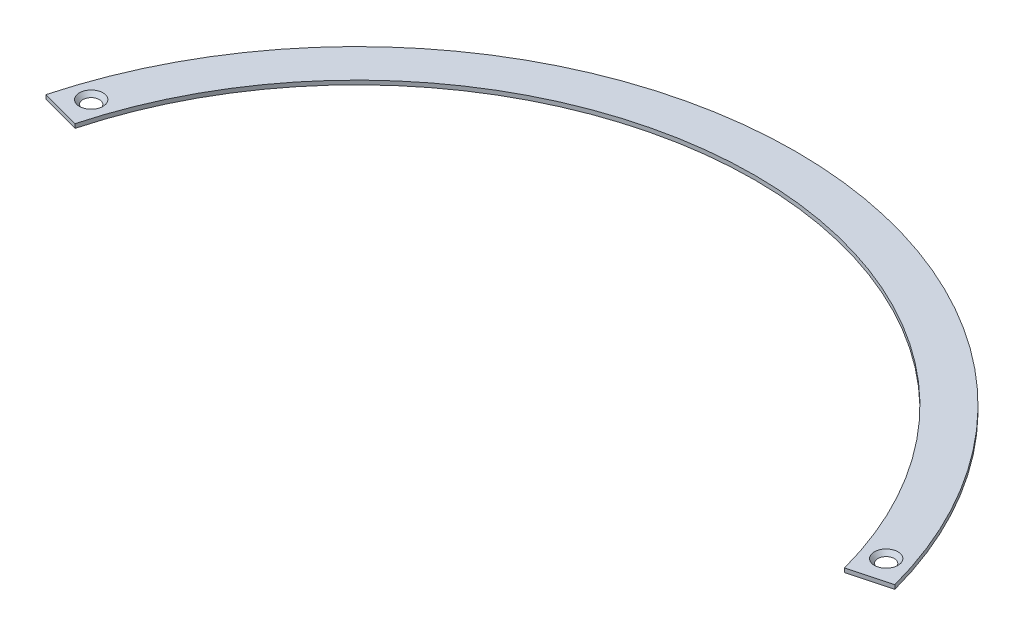
from build123d import *

# Parameters (mm, degrees)
BOSS_EXTRUDE1_DEPTH                           = 1.5875
CSK_FOR_8_FLAT_HEAD_SOCKET_CAP_SCREW1_A_COUNT = 2
CSK_FOR_8_FLAT_HEAD_SOCKET_CAP_SCREW1_A_PITCH = 307.345506508


with BuildPart() as part:
    # Sketch2 → Boss-Extrude1 (new body)
    with BuildSketch(Plane(origin=(0, 0, 0), x_dir=(1, 0, 0), z_dir=(0, 1, 0))):
        with BuildLine():
            Line((-148.740503176, 39.854897708), (-164.074575668, 43.963650049))
            ThreePointArc((-164.074575668, 43.963650049), (0, 169.8625), (164.074575668, 43.963650049))
            Line((164.074575668, 43.963650049), (148.740503176, 39.854897708))
            ThreePointArc((148.740503176, 39.854897708), (0, 153.9875), (-148.740503176, 39.854897708))
        make_face()
    extrude(amount=BOSS_EXTRUDE1_DEPTH)

    # Sketch4 → CSK for #8 Flat Head Socket Cap Screw1 (revolve, cut)
    with BuildSketch(Plane(origin=(-153.672753254, 1.5875, -51.033229688), x_dir=(0, 0, 1), z_dir=(1, 0, 0))):
        Polygon((0, 0), (0, 1.5875), (2.2479, 1.5875), (2.2479, 2.658961536), (4.5593, 0), align=None)
    csk_for_8_flat_head_socket_cap_screw1 = revolve(axis=Axis((-153.672753254, 7.9375, -51.033229688), (0, -1, 0)), mode=Mode.SUBTRACT)

    # CSK for #8 Flat Head Socket Cap Screw1 a: CSK for #8 Flat Head Socket Cap Screw1 ×2
    with Locations(*[(i * CSK_FOR_8_FLAT_HEAD_SOCKET_CAP_SCREW1_A_PITCH, 0, 0) for i in range(1, CSK_FOR_8_FLAT_HEAD_SOCKET_CAP_SCREW1_A_COUNT)]):
        add(csk_for_8_flat_head_socket_cap_screw1, mode=Mode.SUBTRACT)


solid = part.part
